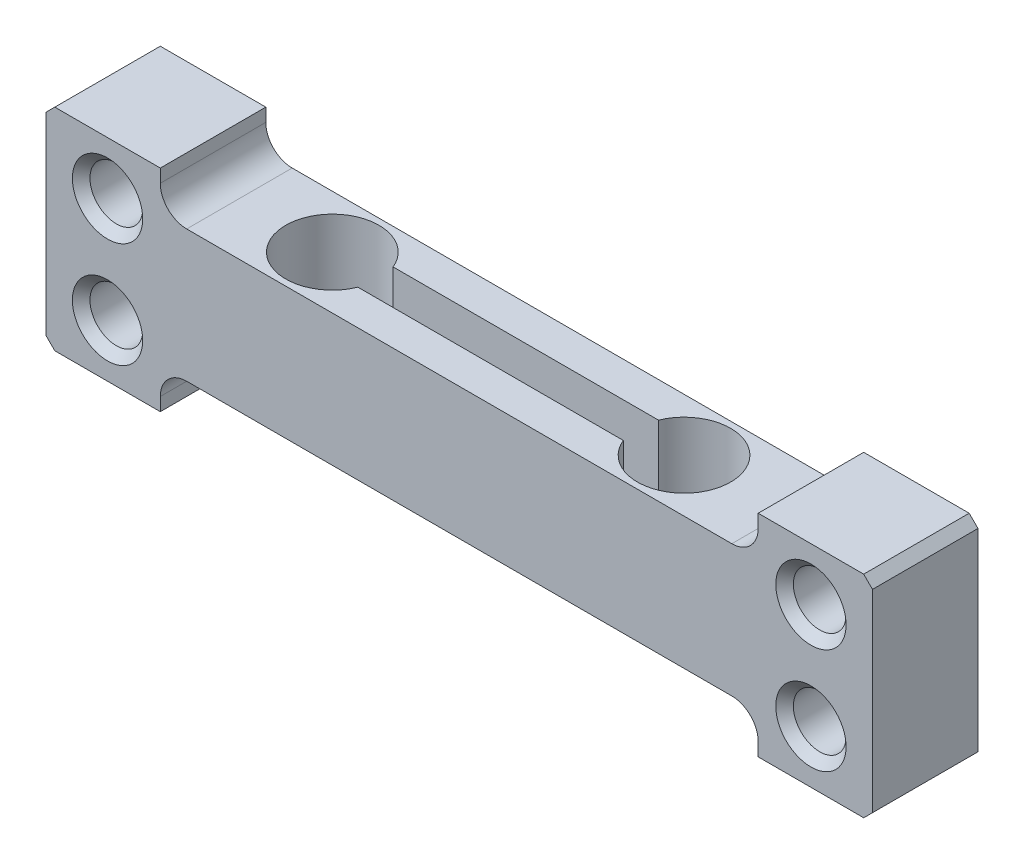
from build123d import *

# Parameters (mm, degrees)
SKETCH_1_R          = 1.5
EXTRUDE_1_DEPTH     = 6
CHAMFER_1_SIZE      = 0.5
CUT_EXTRUDE_1_DEPTH = 10
CHAMFER_2_SIZE      = 0.5


with BuildPart() as part:
    # 草图1 → 凸台-拉伸1 (new body)
    with BuildSketch(Plane.XY):
        with BuildLine():
            Line((40.5, 11.25), (40.5, 12))
            Line((40.5, 12), (47, 12))
            Line((47, 12), (47, 0))
            Line((47, 0), (40.5, 0))
            Line((40.5, 0), (40.5, 0.75))
            ThreePointArc((40.5, 0.75), (40.060660172, 1.810660172), (39, 2.25))
            Line((39, 2.25), (8, 2.25))
            ThreePointArc((8, 2.25), (6.939339828, 1.810660172), (6.5, 0.75))
            Line((6.5, 0.75), (6.5, 0))
            Line((6.5, 0), (0, 0))
            Line((0, 0), (0, 12))
            Line((0, 12), (6.5, 12))
            Line((6.5, 12), (6.5, 11.25))
            ThreePointArc((6.5, 11.25), (6.939339828, 10.189339828), (8, 9.75))
            Line((8, 9.75), (39, 9.75))
            ThreePointArc((39, 9.75), (40.060660172, 10.189339828), (40.5, 11.25))
        make_face()
        with Locations((3.5, 3)):
            Circle(SKETCH_1_R, mode=Mode.SUBTRACT)
        with Locations((3.5, 9)):
            Circle(SKETCH_1_R, mode=Mode.SUBTRACT)
        with Locations((43.5, 3)):
            Circle(SKETCH_1_R, mode=Mode.SUBTRACT)
        with Locations((43.5, 9)):
            Circle(SKETCH_1_R, mode=Mode.SUBTRACT)
    extrude(amount=EXTRUDE_1_DEPTH)

    # 倒角1
    chamfer_1_edges = [part.edges().sort_by_distance(p)[0] for p in [
        (0, 12, 3),
        (47, 12, 3),
        (47, 0, 3),
        (0, 0, 3),
    ]]
    chamfer(chamfer_1_edges, length=CHAMFER_1_SIZE)

    # 草图2 → 切除-拉伸1 (cut)
    with BuildSketch(Plane(origin=(0, 9.75, 0), x_dir=(1, 0, 0), z_dir=(0, 1, 0))):
        with BuildLine():
            Line((30.829472469, -2), (15.737628945, -2))
            ThreePointArc((15.737628945, -2), (10.633550707, -3), (15.737628945, -4))
            Line((15.737628945, -4), (30.829472469, -4))
            ThreePointArc((30.829472469, -4), (35.933550707, -3), (30.829472469, -2))
        make_face()
    extrude(amount=-CUT_EXTRUDE_1_DEPTH, mode=Mode.SUBTRACT)

    # 倒角2
    chamfer_2_edges = [part.edges().sort_by_distance(p)[0] for p in [
        (2, 3, 0),
        (2, 3, 6),
        (2, 9, 0),
        (2, 9, 6),
        (42, 3, 0),
        (42, 3, 6),
        (42, 9, 0),
        (42, 9, 6),
    ]]
    chamfer(chamfer_2_edges, length=CHAMFER_2_SIZE)


solid = part.part
